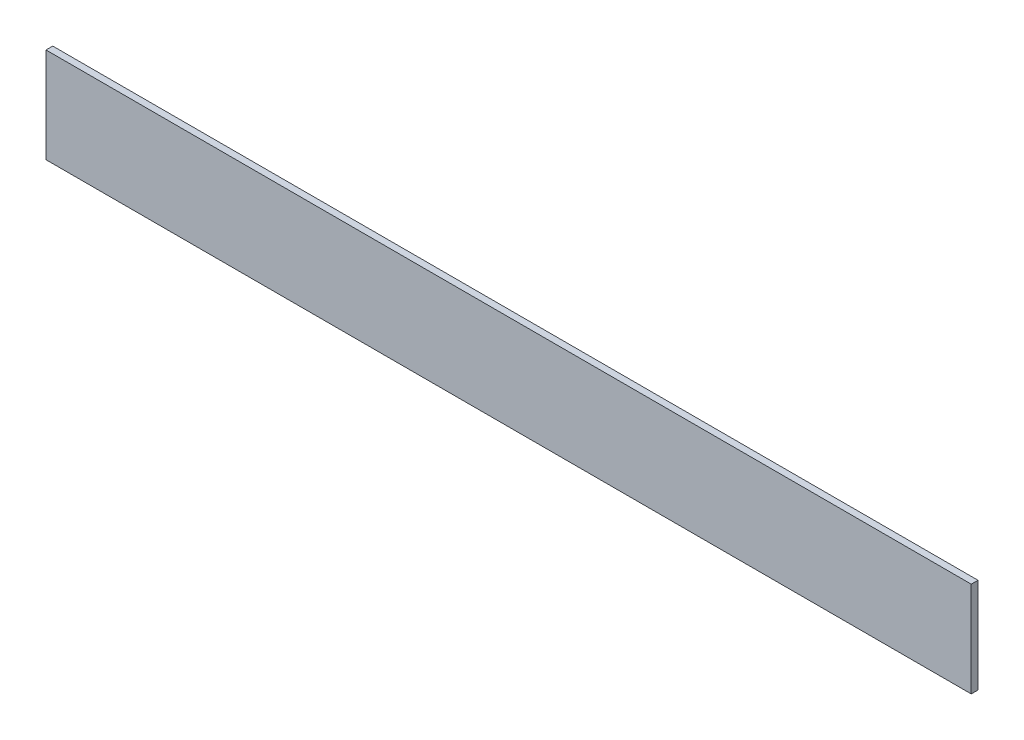
from build123d import *

# Parameters (mm, degrees)
SKETCH1_W           = 434.975
SKETCH1_H           = 44.704
BOSS_EXTRUDE1_DEPTH = 3.175


with BuildPart() as part:
    # Sketch1 → Boss-Extrude1 (new body)
    with BuildSketch(Plane.XY):
        Rectangle(SKETCH1_W, SKETCH1_H)
    extrude(amount=BOSS_EXTRUDE1_DEPTH)


solid = part.part
